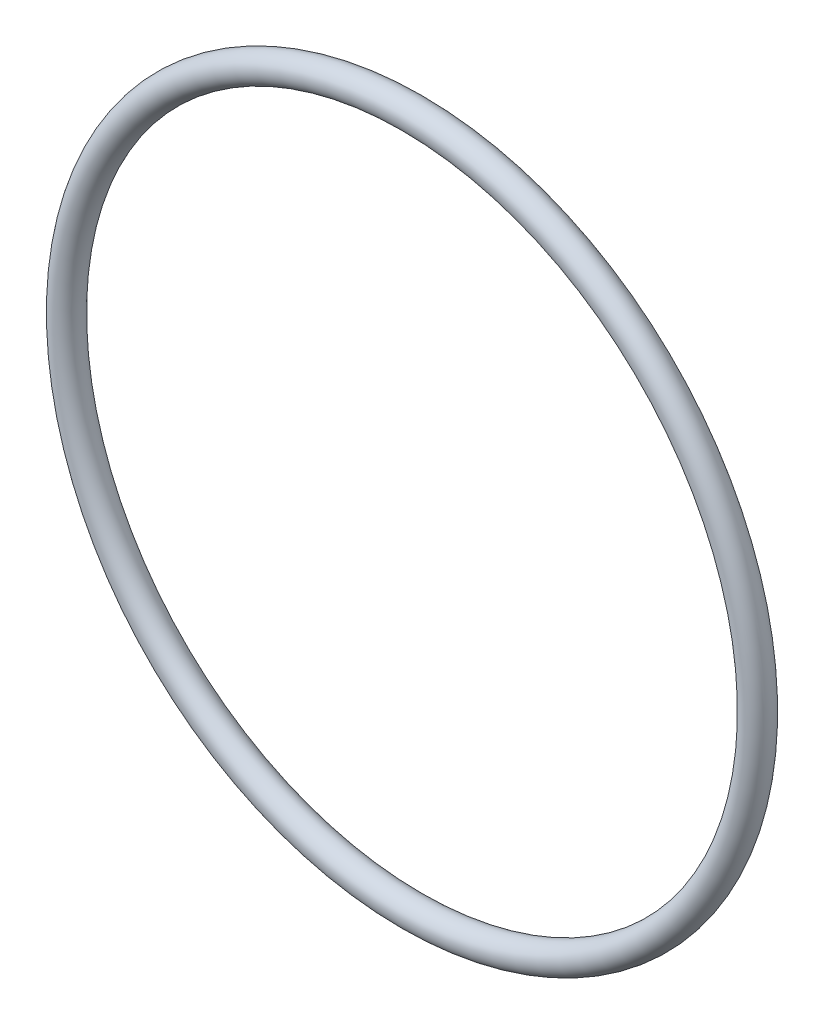
from build123d import *

# Parameters (mm, degrees)
SKETCH2_R = 2.5


with BuildPart() as part:
    # Sweep1: sweep along a path in Sketch1
    with BuildLine(Plane.XY) as sweep1_path:
        CenterArc((0, 0), 60.75, 0, 360)
    # Sketch2 → Sweep1 (sweep)
    with BuildSketch(Plane(origin=(0, 0, 0), x_dir=(0, 0, -1), z_dir=(1, 0, 0))):
        with Locations((0, 60.75)):
            Circle(SKETCH2_R)
    sweep(path=sweep1_path.line)


solid = part.part
